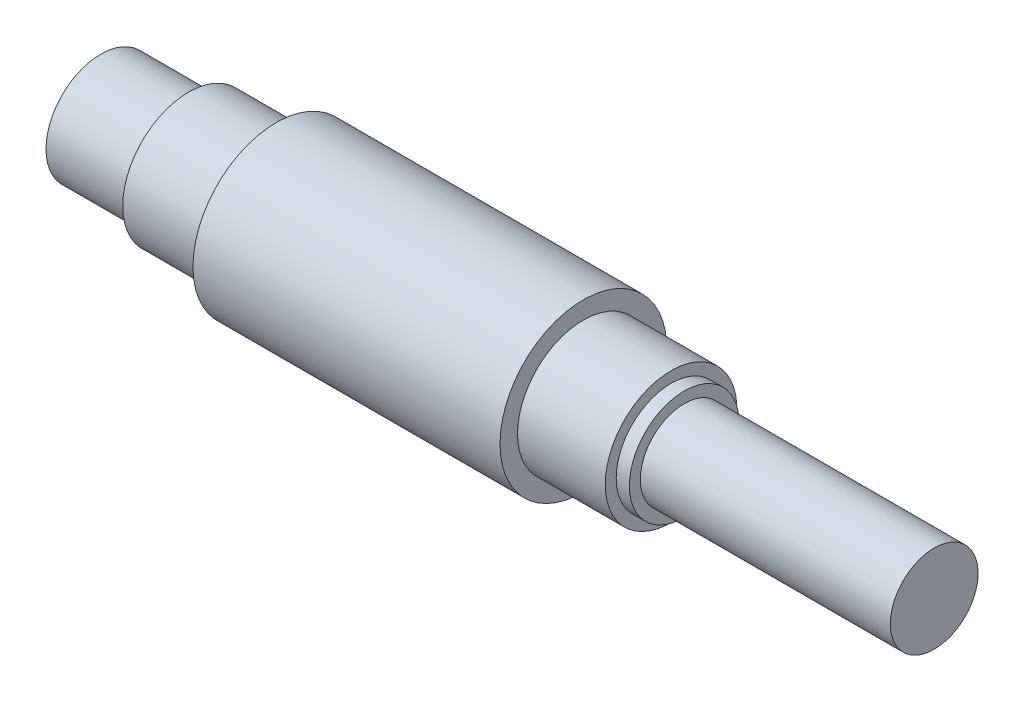
from build123d import *


with BuildPart() as part:
    # Эскиз2 → Повернуть11 (revolve)
    with BuildSketch(Plane.XY):
        Polygon((0, 12.5), (20, 12.5), (20, 15), (40, 15), (40, 19), (110, 19), (110, 15), (130, 15), (130, 12.5), (133, 12.5), (133, 10), (190, 10), (190, 0), (0, 0), align=None)
    revolve(axis=Axis((0, 0, 0), (1, 0, 0)))


solid = part.part
